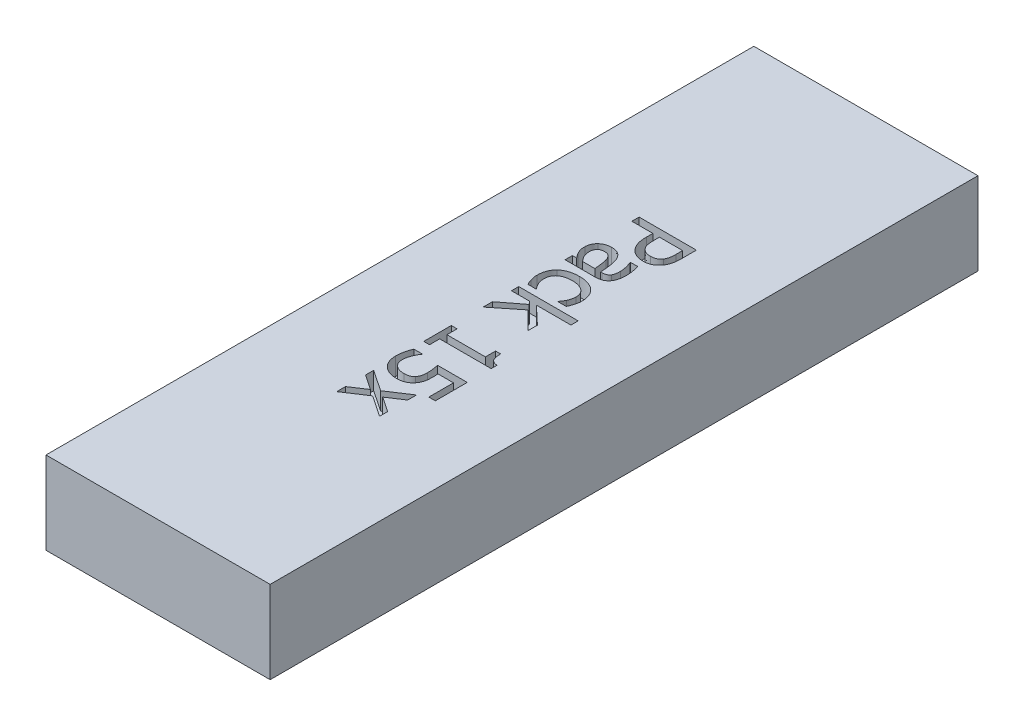
from build123d import *

# Parameters (mm, degrees)
SKETCH1_W           = 38
SKETCH1_H           = 14
BOSS_EXTRUDE1_DEPTH = 120
CUT_EXTRUDE1_DEPTH  = 3


with BuildPart() as part:
    # Sketch1 → Boss-Extrude1 (new body)
    with BuildSketch(Plane.XY):
        Rectangle(SKETCH1_W, SKETCH1_H)
    extrude(amount=BOSS_EXTRUDE1_DEPTH)

    # Sketch2 → Cut-Extrude1 (cut)
    with BuildSketch(Plane(origin=(0, 7, 0), x_dir=(1, 0, 0), z_dir=(0, 1, 0))):
        with BuildLine():
            add(Edge.make_bspline(
                [(3.10361678, -40.946703174), (2.998443262, -40.944520518), (2.789701001, -40.940188509), (2.481945704, -40.893280585), (2.182433634, -40.823454604), (1.894956664, -40.722439287), (1.62109005, -40.59988852), (1.368377071, -40.449571684), (1.132886678, -40.281998706), (0.994513388, -40.150066032), (0.925548373, -40.08431101)],
                knots=[0, 0, 0, 0, 0.000315281, 0.000625751, 0.000931823, 0.001236748, 0.00153845, 0.001830308, 0.002117675, 0.002403207, 0.002403207, 0.002403207, 0.002403207], degree=3))
            add(Edge.make_bspline(
                [(0.925548373, -40.08431101), (0.8444512, -39.997888403), (0.682418389, -39.825215331), (0.481465846, -39.531406966), (0.303598324, -39.220510156), (0.15788989, -38.88212298), (0.045773036, -38.508450782), (-0.033376913, -38.09344963), (-0.081152106, -37.633343369), (-0.086032535, -37.311589629), (-0.088578716, -37.14372659)],
                knots=[0, 0, 0, 0, 0.000355059, 0.00070941, 0.001064619, 0.001428544, 0.001811938, 0.002232693, 0.002694244, 0.0031977, 0.0031977, 0.0031977, 0.0031977], degree=3))
            Line((-0.088578716, -37.14372659), (-0.088578716, -36.029723348))
            Line((-0.088578716, -36.029723348), (-3.65338909, -36.029723348))
            Line((-3.65338909, -36.029723348), (-3.65338909, -34.800478392))
            Line((-3.65338909, -34.800478392), (6.057646066, -34.800478392))
            Line((6.057646066, -34.800478392), (6.057646066, -37.245523438))
            add(Edge.make_bspline(
                [(6.057646066, -37.245523438), (6.055749881, -37.384493735), (6.052102249, -37.651826606), (6.025951361, -38.036687361), (5.979987931, -38.389428487), (5.917427068, -38.712579494), (5.834539163, -39.011149164), (5.728349252, -39.288808333), (5.600921972, -39.549543715), (5.496543229, -39.709466945), (5.444944283, -39.788523942)],
                knots=[0, 0, 0, 0, 0.000416901, 0.000801981, 0.001156478, 0.001483436, 0.001788688, 0.002084755, 0.002374226, 0.002657221, 0.002657221, 0.002657221, 0.002657221], degree=3))
            add(Edge.make_bspline(
                [(5.444944283, -39.788523942), (5.380496835, -39.876085573), (5.252913325, -40.049427119), (5.024427162, -40.277644659), (4.77154826, -40.475563746), (4.495476692, -40.647111607), (4.190450776, -40.783308539), (3.854830634, -40.878246414), (3.489160986, -40.936741242), (3.235094824, -40.943305962), (3.10361678, -40.946703174)],
                knots=[0, 0, 0, 0, 0.000325794, 0.000644959, 0.00096503, 0.00128753, 0.001617694, 0.001963574, 0.00233113, 0.002725341, 0.002725341, 0.002725341, 0.002725341], degree=3))
        make_face()
        with BuildLine():
            add(Edge.make_bspline(
                [(3.072885656, -39.594533722), (3.155579742, -39.59227903), (3.31588274, -39.587908296), (3.547937185, -39.555449441), (3.762483389, -39.499670868), (3.960824494, -39.422489718), (4.142886745, -39.323159264), (4.304942324, -39.197266139), (4.454688409, -39.053791605), (4.534413723, -38.939799603), (4.574869337, -38.881955787)],
                knots=[0, 0, 0, 0, 0.000248038, 0.000480822, 0.000701176, 0.000911612, 0.001117942, 0.001320773, 0.001525856, 0.001737133, 0.001737133, 0.001737133, 0.001737133], degree=3))
            add(Edge.make_bspline(
                [(4.574869337, -38.881955787), (4.608359279, -38.828964833), (4.676355834, -38.721374252), (4.751814922, -38.54326361), (4.81959561, -38.355428829), (4.868163376, -38.150960587), (4.906979113, -37.927796789), (4.933117755, -37.680773961), (4.94779301, -37.408964728), (4.950117205, -37.219292854), (4.951325605, -37.120678247)],
                knots=[0, 0, 0, 0, 0.000187757, 0.000381214, 0.000578635, 0.000786399, 0.001010594, 0.00125791, 0.001531081, 0.001826924, 0.001826924, 0.001826924, 0.001826924], degree=3))
            Line((4.951325605, -37.120678247), (4.951325605, -36.029723348))
            Line((4.951325605, -36.029723348), (1.017741744, -36.029723348))
            Line((1.017741744, -36.029723348), (1.017741744, -36.926688028))
            add(Edge.make_bspline(
                [(1.017741744, -36.926688028), (1.018866537, -37.053502442), (1.021004993, -37.294602058), (1.046214215, -37.637017112), (1.085409561, -37.94125936), (1.139967578, -38.211265932), (1.216532961, -38.451966517), (1.320406851, -38.668612689), (1.447485274, -38.865919009), (1.553143957, -38.979404447), (1.605474489, -39.035611406)],
                knots=[0, 0, 0, 0, 0.000380375, 0.00072317, 0.001029308, 0.001300153, 0.001548577, 0.001784831, 0.002019226, 0.002249237, 0.002249237, 0.002249237, 0.002249237], degree=3))
            add(Edge.make_bspline(
                [(1.605474489, -39.035611406), (1.655008778, -39.082322619), (1.752304784, -39.174073494), (1.914103907, -39.288311872), (2.078601423, -39.38783725), (2.252634325, -39.466123702), (2.438027877, -39.523395335), (2.636556687, -39.565760885), (2.85008224, -39.590798788), (2.997270994, -39.593266167), (3.072885656, -39.594533722)],
                knots=[0, 0, 0, 0, 0.00020401, 0.00040072, 0.00059276, 0.000780173, 0.000971521, 0.001173815, 0.00138847, 0.001615242, 0.001615242, 0.001615242, 0.001615242], degree=3))
        make_face(mode=Mode.SUBTRACT)
        with BuildLine():
            add(Edge.make_bspline(
                [(-2.925445593, -46.109531992), (-2.945982411, -46.082679593), (-2.990400503, -46.024601841), (-3.060855181, -45.930175653), (-3.143527731, -45.824557971), (-3.267551036, -45.673221632), (-3.411721675, -45.477038541), (-3.50516219, -45.308306513), (-3.549671547, -45.227932874)],
                knots=[0, 0, 0, 0, 0.000101416, 0.000219347, 0.000353438, 0.00050372, 0.000806484, 0.001081888, 0.001081888, 0.001081888, 0.001081888], degree=3))
            add(Edge.make_bspline(
                [(-3.549671547, -45.227932874), (-3.600751306, -45.12310695), (-3.699574113, -44.920302702), (-3.798194145, -44.655119379), (-3.85504091, -44.429539855), (-3.878313705, -44.232230807), (-3.896872434, -44.005444636), (-3.898415389, -43.844444903), (-3.899238081, -43.758601012)],
                knots=[0, 0, 0, 0, 0.000349725, 0.000676604, 0.000846637, 0.001046288, 0.001271673, 0.001529111, 0.001529111, 0.001529111, 0.001529111], degree=3))
            add(Edge.make_bspline(
                [(-3.899238081, -43.758601012), (-3.896713344, -43.684882983), (-3.891708142, -43.53873961), (-3.861058937, -43.322162342), (-3.806593991, -43.111890471), (-3.731286841, -42.908258579), (-3.638086611, -42.712948052), (-3.525339797, -42.529527977), (-3.397476152, -42.357054354), (-3.297966901, -42.254305233), (-3.248122394, -42.202837864)],
                knots=[0, 0, 0, 0, 0.00022118, 0.000438482, 0.000654635, 0.000871572, 0.001088916, 0.001302701, 0.001516666, 0.001731407, 0.001731407, 0.001731407, 0.001731407], degree=3))
            add(Edge.make_bspline(
                [(-3.248122394, -42.202837864), (-3.195190927, -42.155706981), (-3.088365894, -42.060588549), (-2.909853282, -41.934943191), (-2.713175253, -41.825698031), (-2.50071967, -41.732767044), (-2.27714867, -41.654826539), (-2.044440893, -41.602452836), (-1.806060741, -41.568045291), (-1.645103272, -41.563583124), (-1.563672664, -41.561325653)],
                knots=[0, 0, 0, 0, 0.000212495, 0.000428853, 0.000653278, 0.000886325, 0.001123816, 0.001362361, 0.001600853, 0.001845053, 0.001845053, 0.001845053, 0.001845053], degree=3))
            add(Edge.make_bspline(
                [(-1.563672664, -41.561325653), (-1.441134775, -41.56464004), (-1.203470034, -41.571068361), (-0.861576413, -41.631170358), (-0.547553505, -41.731127276), (-0.262144092, -41.873084142), (-0.000861295, -42.054899578), (0.225845481, -42.288672005), (0.430053718, -42.563861018), (0.53377021, -42.773927802), (0.58750601, -42.882763981)],
                knots=[0, 0, 0, 0, 0.000367355, 0.000712493, 0.001037454, 0.001352694, 0.001665508, 0.001987389, 0.002325453, 0.002688917, 0.002688917, 0.002688917, 0.002688917], degree=3))
            add(Edge.make_bspline(
                [(0.58750601, -42.882763981), (0.632876783, -42.98834279), (0.726001235, -43.205045485), (0.833758979, -43.552583935), (0.920239087, -43.926962863), (0.98263081, -44.327350591), (1.033160477, -44.749173821), (1.07725935, -45.188474107), (1.113994387, -45.643759633), (1.131681694, -45.952634268), (1.14066624, -46.109531992)],
                knots=[0, 0, 0, 0, 0.000344549, 0.000707195, 0.001089703, 0.001496405, 0.001922128, 0.00236418, 0.002820846, 0.003292297, 0.003292297, 0.003292297, 0.003292297], degree=3))
            Line((1.14066624, -46.109531992), (1.376911755, -46.109531992))
            add(Edge.make_bspline(
                [(1.376911755, -46.109531992), (1.446154998, -46.108453009), (1.577467006, -46.106406841), (1.763981015, -46.080582245), (1.930006823, -46.041609498), (2.076655142, -45.985319761), (2.204942524, -45.914213695), (2.314998571, -45.827577136), (2.413863626, -45.732589319), (2.46400966, -45.657277759), (2.488994302, -45.619754704)],
                knots=[0, 0, 0, 0, 0.000207577, 0.000393647, 0.00056368, 0.000718126, 0.000863453, 0.001001756, 0.00113757, 0.00127243, 0.00127243, 0.00127243, 0.00127243], degree=3))
            add(Edge.make_bspline(
                [(2.488994302, -45.619754704), (2.513045753, -45.579949885), (2.562646084, -45.497862021), (2.618906784, -45.362037485), (2.661548037, -45.213004508), (2.700334822, -44.996837034), (2.732973489, -44.712875309), (2.736767007, -44.482166983), (2.738684684, -44.36554071)],
                knots=[0, 0, 0, 0, 0.000139366, 0.000287409, 0.000439375, 0.000603614, 0.000945741, 0.001295497, 0.001295497, 0.001295497, 0.001295497], degree=3))
            add(Edge.make_bspline(
                [(2.738684684, -44.36554071), (2.737048459, -44.292505601), (2.733639545, -44.140344016), (2.709435843, -43.902965481), (2.66811869, -43.647446459), (2.59320855, -43.279678128), (2.467590676, -42.804203124), (2.321243563, -42.434567712), (2.246986701, -42.247013855)],
                knots=[0, 0, 0, 0, 0.000219094, 0.000456461, 0.000715078, 0.000995329, 0.001582399, 0.002187113, 0.002187113, 0.002187113, 0.002187113], degree=3))
            Line((2.246986701, -42.247013855), (2.246986701, -42.175948131))
            Line((2.246986701, -42.175948131), (3.508883477, -42.175948131))
            add(Edge.make_bspline(
                [(3.508883477, -42.175948131), (3.52582871, -42.23797243), (3.562909546, -42.373698668), (3.616290398, -42.596534982), (3.6714107, -42.856008434), (3.728319541, -43.145113936), (3.779651124, -43.451632013), (3.819273063, -43.763505171), (3.839797295, -44.07395298), (3.843277553, -44.280364699), (3.845005144, -44.382826967)],
                knots=[0, 0, 0, 0, 0.000192884, 0.000422083, 0.000687292, 0.00098864, 0.001305979, 0.001619494, 0.001931363, 0.00223877, 0.00223877, 0.00223877, 0.00223877], degree=3))
            add(Edge.make_bspline(
                [(3.845005144, -44.382826967), (3.843379987, -44.501929226), (3.84025799, -44.730729678), (3.820880347, -45.059276915), (3.781457259, -45.358553356), (3.731113464, -45.632647032), (3.660234448, -45.886124268), (3.563785798, -46.122689602), (3.449143506, -46.349086112), (3.350655072, -46.486485806), (3.30144839, -46.555133288)],
                knots=[0, 0, 0, 0, 0.000357332, 0.00068645, 0.000986625, 0.001262364, 0.001521971, 0.001774489, 0.002027919, 0.002280963, 0.002280963, 0.002280963, 0.002280963], degree=3))
            add(Edge.make_bspline(
                [(3.30144839, -46.555133288), (3.249318627, -46.618145147), (3.145059099, -46.744168864), (2.958828564, -46.905438386), (2.750691968, -47.041477196), (2.519910039, -47.151294976), (2.264923728, -47.235721817), (1.984985128, -47.296669877), (1.678150092, -47.333236548), (1.464728468, -47.336882832), (1.353863412, -47.338776948)],
                knots=[0, 0, 0, 0, 0.000245007, 0.000490014, 0.000735601, 0.000989031, 0.001254455, 0.001539657, 0.001847221, 0.002179701, 0.002179701, 0.002179701, 0.002179701], degree=3))
            Line((1.353863412, -47.338776948), (-3.65338909, -47.338776948))
            Line((-3.65338909, -47.338776948), (-3.65338909, -46.109531992))
            Line((-3.65338909, -46.109531992), (-2.925445593, -46.109531992))
        make_face()
        with BuildLine():
            Line((-1.915159894, -46.109531992), (0.157270275, -46.109531992))
            add(Edge.make_bspline(
                [(0.157270275, -46.109531992), (0.150509513, -46.031396335), (0.136202947, -45.866052112), (0.107450371, -45.603865507), (0.080430919, -45.312886028), (0.046061134, -45.003048709), (0.010553869, -44.693943773), (-0.032789784, -44.406685996), (-0.083284332, -44.151101345), (-0.127353587, -43.993979623), (-0.148120269, -43.919939413)],
                knots=[0, 0, 0, 0, 0.000235275, 0.00049787, 0.000791234, 0.001111938, 0.00143308, 0.001724551, 0.001983332, 0.002213952, 0.002213952, 0.002213952, 0.002213952], degree=3))
            add(Edge.make_bspline(
                [(-0.148120269, -43.919939413), (-0.175122967, -43.841118693), (-0.227942963, -43.686937426), (-0.336089674, -43.472317919), (-0.467113632, -43.281022664), (-0.613051027, -43.106867459), (-0.789491559, -42.963033092), (-0.999885795, -42.862217903), (-1.239915364, -42.7990812), (-1.41087519, -42.793493211), (-1.500289721, -42.790570609)],
                knots=[0, 0, 0, 0, 0.000249757, 0.00048855, 0.000718151, 0.00094419, 0.001168262, 0.001395034, 0.001639144, 0.001906811, 0.001906811, 0.001906811, 0.001906811], degree=3))
            add(Edge.make_bspline(
                [(-1.500289721, -42.790570609), (-1.552173682, -42.791821619), (-1.652337769, -42.794236743), (-1.798540161, -42.808731994), (-1.933905448, -42.838052508), (-2.060931867, -42.876282049), (-2.177342071, -42.926111609), (-2.285482665, -42.985650979), (-2.381008277, -43.059673465), (-2.497913441, -43.170330654), (-2.619830867, -43.340336297), (-2.720723097, -43.583980095), (-2.782271722, -43.866999754), (-2.789237172, -44.068776056), (-2.792917621, -44.17539188)],
                knots=[0, 0, 0, 0, 0.000155683, 0.000300552, 0.000439932, 0.000570553, 0.000697914, 0.000819177, 0.000939799, 0.001059346, 0.001301384, 0.001560393, 0.001845595, 0.00216513, 0.00216513, 0.00216513, 0.00216513], degree=3))
            add(Edge.make_bspline(
                [(-2.792917621, -44.17539188), (-2.790338328, -44.270387548), (-2.785284182, -44.456532404), (-2.734372285, -44.728369848), (-2.65759642, -44.987547306), (-2.542322998, -45.230380111), (-2.40755979, -45.461990685), (-2.256140503, -45.685119815), (-2.093949397, -45.902888099), (-1.974929003, -46.040451195), (-1.915159894, -46.109531992)],
                knots=[0, 0, 0, 0, 0.000284678, 0.000557829, 0.00082698, 0.001093396, 0.001361889, 0.001630374, 0.001901961, 0.002175921, 0.002175921, 0.002175921, 0.002175921], degree=3))
        make_face(mode=Mode.SUBTRACT)
        with BuildLine():
            add(Edge.make_bspline(
                [(-3.776313586, -51.954207621), (-3.773133966, -51.831812324), (-3.76690517, -51.592042979), (-3.72464484, -51.239508078), (-3.651148623, -50.903630234), (-3.551978468, -50.582596843), (-3.422209997, -50.280221386), (-3.258666417, -50.000517779), (-3.06955097, -49.739439297), (-2.91857933, -49.587361649), (-2.842855697, -49.51108327)],
                knots=[0, 0, 0, 0, 0.000367174, 0.000719286, 0.00106324, 0.001397353, 0.001725971, 0.00204783, 0.002367826, 0.002689845, 0.002689845, 0.002689845, 0.002689845], degree=3))
            add(Edge.make_bspline(
                [(-2.842855697, -49.51108327), (-2.761159809, -49.438747164), (-2.595106957, -49.291718752), (-2.312715252, -49.103504476), (-1.998065191, -48.945019972), (-1.655638859, -48.807370369), (-1.280264839, -48.700725809), (-0.874330727, -48.622119874), (-0.436636546, -48.576294614), (-0.134784743, -48.570836848), (0.020900913, -48.568021905)],
                knots=[0, 0, 0, 0, 0.000327083, 0.000664819, 0.001014433, 0.001382511, 0.001770339, 0.002183186, 0.002621614, 0.003088596, 0.003088596, 0.003088596, 0.003088596], degree=3))
            add(Edge.make_bspline(
                [(0.020900913, -48.568021905), (0.175332538, -48.570632122), (0.47475047, -48.575692912), (0.907218378, -48.624161111), (1.30771459, -48.703101953), (1.674340902, -48.818494901), (2.012132905, -48.956075597), (2.320543775, -49.118856996), (2.603859912, -49.299416927), (2.771495839, -49.441310726), (2.853926398, -49.51108327)],
                knots=[0, 0, 0, 0, 0.000463143, 0.000897958, 0.001303644, 0.001685765, 0.002049224, 0.002396312, 0.002730872, 0.003054536, 0.003054536, 0.003054536, 0.003054536], degree=3))
            add(Edge.make_bspline(
                [(2.853926398, -49.51108327), (2.930863869, -49.584760103), (3.085687264, -49.733022028), (3.28219843, -49.991174638), (3.452793351, -50.273935147), (3.593543692, -50.581086763), (3.706513001, -50.905825938), (3.787479059, -51.244827998), (3.836829492, -51.59549105), (3.842258219, -51.833682967), (3.845005144, -51.954207621)],
                knots=[0, 0, 0, 0, 0.000319165, 0.000642265, 0.000969685, 0.001308273, 0.001653897, 0.001999563, 0.002352412, 0.00271383, 0.00271383, 0.00271383, 0.00271383], degree=3))
            add(Edge.make_bspline(
                [(3.845005144, -51.954207621), (3.843595679, -52.053555987), (3.840805166, -52.250249692), (3.80517833, -52.541976458), (3.755601941, -52.828962913), (3.678598159, -53.107505482), (3.591084967, -53.375482725), (3.49555897, -53.630573747), (3.398340357, -53.872392441), (3.322878187, -54.025143018), (3.286082828, -54.099624209)],
                knots=[0, 0, 0, 0, 0.000297863, 0.00058972, 0.000880564, 0.001170818, 0.001455684, 0.00172612, 0.001987927, 0.002237063, 0.002237063, 0.002237063, 0.002237063], degree=3))
            Line((3.286082828, -54.099624209), (1.878213214, -54.099624209))
            Line((1.878213214, -54.099624209), (1.878213214, -54.02663779))
            add(Edge.make_bspline(
                [(1.878213214, -54.02663779), (1.917692853, -53.977023362), (2.004633208, -53.867764611), (2.137786193, -53.679837647), (2.281812363, -53.451219372), (2.370643352, -53.278978653), (2.417928578, -53.187293968)],
                knots=[0, 0, 0, 0, 0.000190188, 0.000418823, 0.00069062, 0.000999965, 0.000999965, 0.000999965, 0.000999965], degree=3))
            add(Edge.make_bspline(
                [(2.417928578, -53.187293968), (2.460271095, -53.095229687), (2.550131317, -52.899848842), (2.646891944, -52.582442876), (2.725488318, -52.251035828), (2.734383384, -52.02506445), (2.738684684, -51.915793716)],
                knots=[0, 0, 0, 0, 0.000303652, 0.000644417, 0.000994005, 0.001321336, 0.001321336, 0.001321336, 0.001321336], degree=3))
            add(Edge.make_bspline(
                [(2.738684684, -51.915793716), (2.736421982, -51.837574024), (2.73200583, -51.68491137), (2.698833138, -51.46128187), (2.643056462, -51.250204917), (2.566673558, -51.04923199), (2.462755882, -50.863465361), (2.342356014, -50.686347973), (2.195384364, -50.524275233), (2.029222437, -50.373205537), (1.84269733, -50.235912359), (1.635567397, -50.119361356), (1.411258818, -50.018856831), (1.16888256, -49.936557028), (0.907925028, -49.873081458), (0.628356085, -49.830148717), (0.330674778, -49.802800718), (0.125961404, -49.799143681), (0.020900913, -49.797266861)],
                knots=[0, 0, 0, 0, 0.000234608, 0.000457888, 0.000676384, 0.00088861, 0.001100914, 0.001313496, 0.001529785, 0.001755498, 0.001986381, 0.002222946, 0.002467109, 0.002722821, 0.002989749, 0.003271732, 0.003570652, 0.003885792, 0.003885792, 0.003885792, 0.003885792], degree=3))
            add(Edge.make_bspline(
                [(0.020900913, -49.797266861), (-0.082214448, -49.799397931), (-0.282989273, -49.803547314), (-0.575220198, -49.827352656), (-0.849776505, -49.87225048), (-1.107042336, -49.932470669), (-1.347083309, -50.012230059), (-1.570941376, -50.106618585), (-1.77477362, -50.223731649), (-1.962860636, -50.352939482), (-2.12722459, -50.501997688), (-2.273814473, -50.662198407), (-2.397065849, -50.837737476), (-2.497872931, -51.02737274), (-2.574457332, -51.230992632), (-2.630566611, -51.447190427), (-2.663231965, -51.67727535), (-2.667703499, -51.835020891), (-2.669993125, -51.915793716)],
                knots=[0, 0, 0, 0, 0.000309381, 0.000602393, 0.000878686, 0.001143296, 0.001394143, 0.00163676, 0.001870707, 0.002098234, 0.002319948, 0.002534808, 0.002748489, 0.002961574, 0.003177385, 0.003399597, 0.00363048, 0.003872762, 0.003872762, 0.003872762, 0.003872762], degree=3))
            add(Edge.make_bspline(
                [(-2.669993125, -51.915793716), (-2.666939154, -52.015192611), (-2.660879708, -52.21241193), (-2.615248629, -52.50476926), (-2.540617668, -52.790149608), (-2.434370618, -53.065245854), (-2.304586553, -53.32790215), (-2.159814817, -53.578456299), (-1.993974319, -53.811555536), (-1.870802665, -53.955180662), (-1.809521655, -54.02663779)],
                knots=[0, 0, 0, 0, 0.000298104, 0.000591474, 0.000885441, 0.001181508, 0.001474426, 0.001763654, 0.002048779, 0.002331095, 0.002331095, 0.002331095, 0.002331095], degree=3))
            Line((-1.809521655, -54.02663779), (-1.809521655, -54.099624209))
            Line((-1.809521655, -54.099624209), (-3.205867098, -54.099624209))
            add(Edge.make_bspline(
                [(-3.205867098, -54.099624209), (-3.237322712, -54.031153317), (-3.306826679, -53.879860812), (-3.413269452, -53.643199186), (-3.515943846, -53.397347658), (-3.565094892, -53.22937194), (-3.588085452, -53.150800758)],
                knots=[0, 0, 0, 0, 0.000226039, 0.000499453, 0.000778721, 0.00102415, 0.00102415, 0.00102415, 0.00102415], degree=3))
            add(Edge.make_bspline(
                [(-3.588085452, -53.150800758), (-3.61569276, -53.052409037), (-3.667593446, -52.867436357), (-3.722198718, -52.636729215), (-3.751614443, -52.453485893), (-3.766774177, -52.302809446), (-3.773294984, -52.134167414), (-3.77527185, -52.01631275), (-3.776313586, -51.954207621)],
                knots=[0, 0, 0, 0, 0.00030659, 0.000576378, 0.000710579, 0.00086309, 0.001030367, 0.001216714, 0.001216714, 0.001216714, 0.001216714], degree=3))
        make_face()
        Polygon((-3.65338909, -61.229244956), (-3.65338909, -59.654274856), (-0.138516793, -56.942253171), (-0.620611299, -56.435189626), (-3.65338909, -56.435189626), (-3.65338909, -55.20594467), (6.426419553, -55.20594467), (6.426419553, -56.435189626), (0.570219753, -56.435189626), (3.599156153, -59.291263455), (3.599156153, -60.86047147), (0.566378362, -57.856504107), align=None)
        with BuildLine():
            Line((-3.65338909, -71.3090536), (-3.65338909, -66.637922765))
            Line((-3.65338909, -66.637922765), (-2.669993125, -66.637922765))
            Line((-2.669993125, -66.637922765), (-2.669993125, -68.358865704))
            Line((-2.669993125, -68.358865704), (3.845005144, -68.358865704))
            Line((3.845005144, -68.358865704), (3.845005144, -66.637922765))
            Line((3.845005144, -66.637922765), (4.705476614, -66.637922765))
            add(Edge.make_bspline(
                [(4.705476614, -66.637922765), (4.706016986, -66.716691136), (4.707059068, -66.868592171), (4.72053978, -67.088478153), (4.743541929, -67.292277394), (4.774348024, -67.480694913), (4.810766669, -67.654205102), (4.861873773, -67.810321645), (4.918661064, -67.950780194), (4.984292075, -68.076950238), (5.063799069, -68.188153528), (5.159102764, -68.285203044), (5.270677313, -68.368929612), (5.397972266, -68.438890842), (5.539700863, -68.499715942), (5.698481271, -68.545072609), (5.872921904, -68.577080095), (5.994787792, -68.588975556), (6.057646066, -68.595111219)],
                knots=[0, 0, 0, 0, 0.000236277, 0.000455648, 0.000660543, 0.000851263, 0.001028342, 0.001191737, 0.001343326, 0.00148252, 0.00161738, 0.001751842, 0.00188898, 0.002034307, 0.002186636, 0.002350741, 0.002528548, 0.002717958, 0.002717958, 0.002717958, 0.002717958], degree=3))
            Line((6.057646066, -68.595111219), (6.057646066, -69.588110661))
            Line((6.057646066, -69.588110661), (-2.669993125, -69.588110661))
            Line((-2.669993125, -69.588110661), (-2.669993125, -71.3090536))
            Line((-2.669993125, -71.3090536), (-3.65338909, -71.3090536))
        make_face()
        with BuildLine():
            add(Edge.make_bspline(
                [(-0.59180087, -79.053296826), (-0.707821745, -79.050989011), (-0.935545056, -79.046459281), (-1.271072074, -79.002457609), (-1.593218271, -78.932235007), (-1.90143564, -78.833464089), (-2.192841565, -78.712203267), (-2.46382345, -78.563751528), (-2.716725624, -78.397094682), (-2.86788264, -78.265614076), (-2.94273185, -78.200508137)],
                knots=[0, 0, 0, 0, 0.000347906, 0.000682862, 0.001013272, 0.001335817, 0.001652586, 0.00195855, 0.002261661, 0.002558978, 0.002558978, 0.002558978, 0.002558978], degree=3))
            add(Edge.make_bspline(
                [(-2.94273185, -78.200508137), (-3.015110804, -78.129919314), (-3.160835784, -77.987798516), (-3.345394079, -77.74040993), (-3.51006441, -77.472016974), (-3.650284518, -77.180270886), (-3.761740241, -76.866117745), (-3.842072428, -76.532789941), (-3.891374136, -76.180773458), (-3.896577738, -75.940013824), (-3.899238081, -75.816925339)],
                knots=[0, 0, 0, 0, 0.000302892, 0.000609831, 0.000922769, 0.001246638, 0.00157894, 0.001920873, 0.002273722, 0.002642815, 0.002642815, 0.002642815, 0.002642815], degree=3))
            add(Edge.make_bspline(
                [(-3.899238081, -75.816925339), (-3.897355741, -75.700991372), (-3.893606047, -75.470046496), (-3.864456179, -75.124851429), (-3.813498014, -74.783434915), (-3.747653937, -74.447162413), (-3.663347639, -74.124407545), (-3.568400378, -73.81984245), (-3.458865903, -73.538541238), (-3.375244606, -73.361833307), (-3.33455368, -73.27584553)],
                knots=[0, 0, 0, 0, 0.000347778, 0.000692788, 0.0010383, 0.001382961, 0.001720239, 0.002038542, 0.002339577, 0.002624908, 0.002624908, 0.002624908, 0.002624908], degree=3))
            Line((-3.33455368, -73.27584553), (-1.932446151, -73.27584553))
            Line((-1.932446151, -73.27584553), (-1.932446151, -73.366118207))
            add(Edge.make_bspline(
                [(-1.932446151, -73.366118207), (-1.953327012, -73.393372362), (-1.998411153, -73.452217167), (-2.062102206, -73.55311134), (-2.133885464, -73.667195458), (-2.232142592, -73.845828589), (-2.356452289, -74.091220469), (-2.441623895, -74.299552624), (-2.485606382, -74.407135029)],
                knots=[0, 0, 0, 0, 0.00010295, 0.000222281, 0.000357673, 0.00050729, 0.000833695, 0.001182236, 0.001182236, 0.001182236, 0.001182236], degree=3))
            add(Edge.make_bspline(
                [(-2.485606382, -74.407135029), (-2.529595558, -74.528391023), (-2.613174938, -74.758777263), (-2.718216077, -75.10228325), (-2.782010323, -75.453431074), (-2.789163388, -75.69307217), (-2.792917621, -75.818846034)],
                knots=[0, 0, 0, 0, 0.000386957, 0.000735218, 0.001076572, 0.001453621, 0.001453621, 0.001453621, 0.001453621], degree=3))
            add(Edge.make_bspline(
                [(-2.792917621, -75.818846034), (-2.790722871, -75.882931805), (-2.786339401, -76.010927309), (-2.761643074, -76.20222669), (-2.716300265, -76.390883358), (-2.656191857, -76.577080968), (-2.574835306, -76.755595733), (-2.468041365, -76.920442368), (-2.344867783, -77.076442334), (-2.244438869, -77.16476985), (-2.193660704, -77.209429391)],
                knots=[0, 0, 0, 0, 0.000192309, 0.000384091, 0.000577433, 0.000773617, 0.000970411, 0.00116383, 0.001361811, 0.001564287, 0.001564287, 0.001564287, 0.001564287], degree=3))
            add(Edge.make_bspline(
                [(-2.193660704, -77.209429391), (-2.143872886, -77.24833422), (-2.044031659, -77.326351414), (-1.87873916, -77.423629066), (-1.702880445, -77.508696727), (-1.513874491, -77.581089024), (-1.308587844, -77.633098138), (-1.088148423, -77.674778063), (-0.849624417, -77.696843161), (-0.684673827, -77.699668304), (-0.599483651, -77.701127373)],
                knots=[0, 0, 0, 0, 0.000189381, 0.000379772, 0.000573914, 0.000775111, 0.000985688, 0.001208331, 0.00144761, 0.001703178, 0.001703178, 0.001703178, 0.001703178], degree=3))
            add(Edge.make_bspline(
                [(-0.599483651, -77.701127373), (-0.516844215, -77.699038883), (-0.358211816, -77.695029875), (-0.131556764, -77.67164709), (0.071966096, -77.62760858), (0.253819064, -77.565719987), (0.416584987, -77.486121034), (0.563605906, -77.39148022), (0.696290548, -77.281944333), (0.771058928, -77.196424014), (0.808385963, -77.153729229)],
                knots=[0, 0, 0, 0, 0.000247956, 0.000475969, 0.000682424, 0.000871327, 0.001050858, 0.00122454, 0.001394963, 0.001564866, 0.001564866, 0.001564866, 0.001564866], degree=3))
            add(Edge.make_bspline(
                [(0.808385963, -77.153729229), (0.848819387, -77.105444651), (0.930053289, -77.008437171), (1.028117158, -76.842377219), (1.106572052, -76.661502074), (1.165832666, -76.465215362), (1.208366719, -76.255943028), (1.241622216, -76.034204309), (1.260764062, -75.800620434), (1.262636933, -75.640895697), (1.263590736, -75.559552176)],
                knots=[0, 0, 0, 0, 0.000188678, 0.00037907, 0.000576042, 0.000778964, 0.000992929, 0.00121621, 0.00145132, 0.001695317, 0.001695317, 0.001695317, 0.001695317], degree=3))
            add(Edge.make_bspline(
                [(1.263590736, -75.559552176), (1.259823416, -75.382624479), (1.252249772, -75.026937334), (1.193570404, -74.588899857), (1.13678963, -74.252630782), (1.096443923, -74.025976684), (1.059223, -73.825806764), (1.030915802, -73.702162544), (1.017741744, -73.644619017)],
                knots=[0, 0, 0, 0, 0.000530533, 0.001066558, 0.001323587, 0.00155379, 0.001757203, 0.001934282, 0.001934282, 0.001934282, 0.001934282], degree=3))
            Line((1.017741744, -73.644619017), (6.057646066, -73.644619017))
            Line((6.057646066, -73.644619017), (6.057646066, -79.053296826))
            Line((6.057646066, -79.053296826), (4.951325605, -79.053296826))
            Line((4.951325605, -79.053296826), (4.951325605, -74.873863973))
            Line((4.951325605, -74.873863973), (2.318052425, -74.873863973))
            add(Edge.make_bspline(
                [(2.318052425, -74.873863973), (2.326307198, -74.952563997), (2.342661794, -75.10848676), (2.356802795, -75.338551636), (2.367041039, -75.556902799), (2.368984165, -75.697831815), (2.369911197, -75.765066567)],
                knots=[0, 0, 0, 0, 0.000237367, 0.000470279, 0.000691367, 0.000893077, 0.000893077, 0.000893077, 0.000893077], degree=3))
            add(Edge.make_bspline(
                [(2.369911197, -75.765066567), (2.368452979, -75.885455842), (2.365642234, -76.117508628), (2.343899803, -76.45119378), (2.302295254, -76.75610926), (2.251053995, -77.037284078), (2.171953284, -77.30127472), (2.06602471, -77.555943973), (1.928609486, -77.805308019), (1.817657891, -77.96270684), (1.761050804, -78.043011127)],
                knots=[0, 0, 0, 0, 0.000361172, 0.000696167, 0.001002306, 0.001284066, 0.001552661, 0.001827321, 0.002110139, 0.002404733, 0.002404733, 0.002404733, 0.002404733], degree=3))
            add(Edge.make_bspline(
                [(1.761050804, -78.043011127), (1.698564085, -78.121855548), (1.574600847, -78.278269744), (1.350569922, -78.476765853), (1.110625944, -78.654863913), (0.841162279, -78.800365227), (0.539324368, -78.915321413), (0.199355826, -78.996770101), (-0.182671196, -79.043627758), (-0.45081316, -79.049964826), (-0.59180087, -79.053296826)],
                knots=[0, 0, 0, 0, 0.000301255, 0.000597641, 0.00089461, 0.001196282, 0.001513033, 0.001861018, 0.00224243, 0.002665336, 0.002665336, 0.002665336, 0.002665336], degree=3))
        make_face()
        Polygon((-3.65338909, -86.059993078), (-3.65338909, -84.569533568), (-1.104626501, -82.887004534), (-3.65338909, -81.169902985), (-3.65338909, -79.790843799), (-0.067451069, -82.207078417), (3.599156153, -79.790843799), (3.599156153, -81.283224004), (1.048472868, -82.961911648), (3.599156153, -84.682854587), (3.599156153, -86.059993078), (0.017059522, -83.64375846), align=None)
    extrude(amount=-CUT_EXTRUDE1_DEPTH, mode=Mode.SUBTRACT)


solid = part.part
